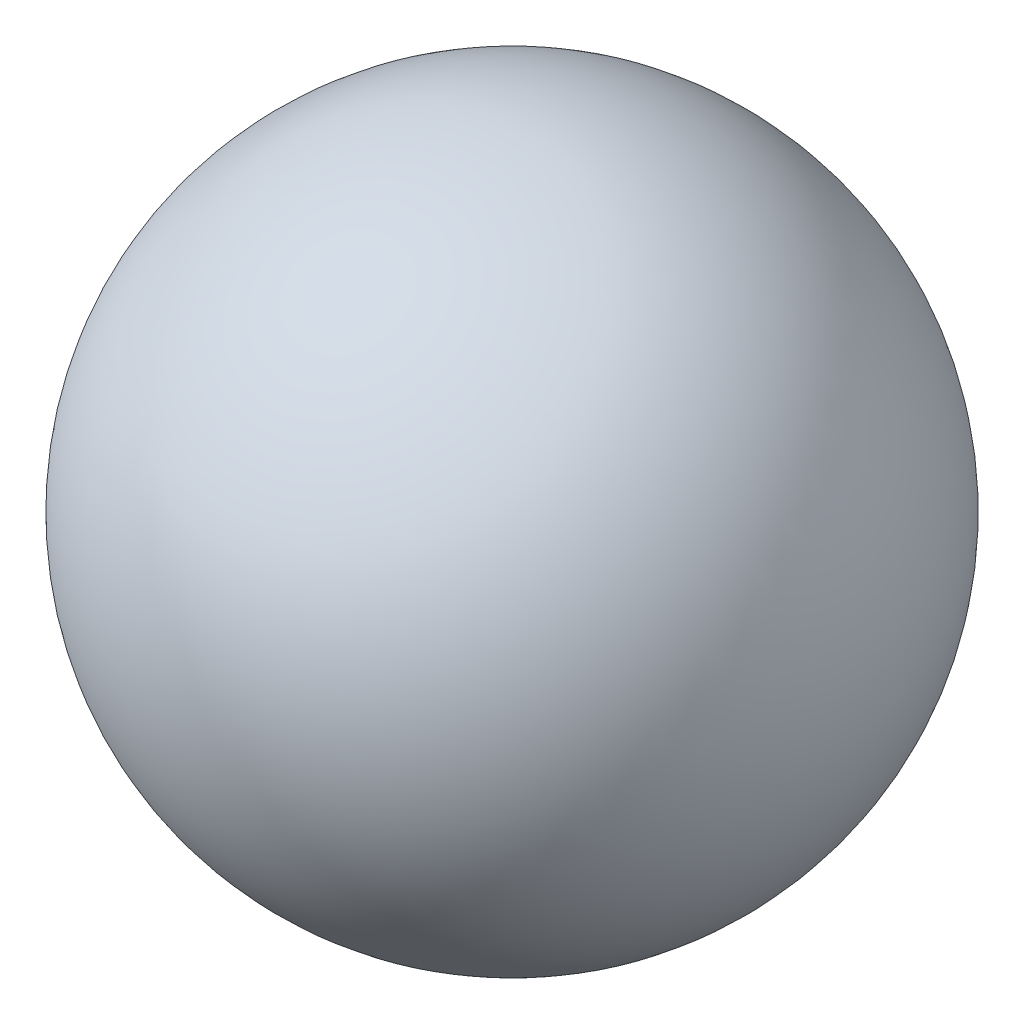
from build123d import *


with BuildPart() as part:
    # 草图1 → 旋转1 (revolve)
    with BuildSketch(Plane.XY):
        with BuildLine():
            Line((0, 25), (0, -25))
            ThreePointArc((0, -25), (-25, 0), (0, 25))
        make_face()
    revolve(axis=Axis((0, 25, 0), (0, -1, 0)))


solid = part.part
